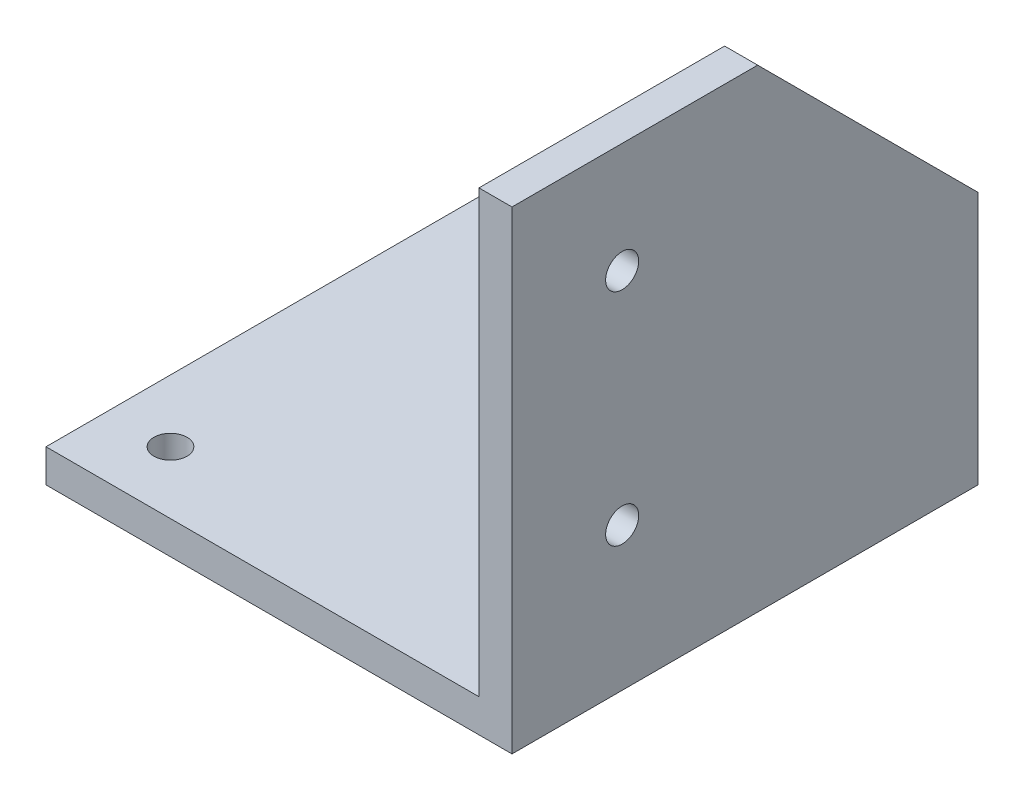
from build123d import *

# Parameters (mm, degrees)
SKETCH1_W           = 42.3
SKETCH1_H           = 42.3
BOSS_EXTRUDE1_DEPTH = 3
SKETCH2_R           = 1.5
CUT_EXTRUDE1_DEPTH  = 4
SKETCH5_W           = 3
SKETCH5_H           = 42.3
BOSS_EXTRUDE2_DEPTH = 40
CUT_EXTRUDE2_DEPTH  = 40
SKETCH7_R           = 1.5
CUT_EXTRUDE3_DEPTH  = 4


with BuildPart() as part:
    # Sketch1 → Boss-Extrude1 (new body)
    with BuildSketch(Plane(origin=(0, 0, 0), x_dir=(1, 0, 0), z_dir=(0, 1, 0))):
        with Locations((21.15, 21.15)):
            Rectangle(SKETCH1_W, SKETCH1_H)
    extrude(amount=BOSS_EXTRUDE1_DEPTH)

    # Sketch2 → Cut-Extrude1 (cut, through all)
    with BuildSketch(Plane(origin=(0, 3, 0), x_dir=(1, 0, 0), z_dir=(0, 1, 0))):
        with Locations((5.65, 5.65)):
            Circle(SKETCH2_R)
        with Locations((36.65, 5.65)):
            Circle(SKETCH2_R)
        with Locations((36.65, 36.65)):
            Circle(SKETCH2_R)
        with Locations((5.65, 36.65)):
            Circle(SKETCH2_R)
    extrude(amount=-CUT_EXTRUDE1_DEPTH, mode=Mode.SUBTRACT)

    # Sketch5 → Boss-Extrude2 (add)
    with BuildSketch(Plane(origin=(0, 3, 0), x_dir=(1, 0, 0), z_dir=(0, 1, 0))):
        with Locations((40.8, 21.15)):
            Rectangle(SKETCH5_W, SKETCH5_H)
    extrude(amount=BOSS_EXTRUDE2_DEPTH)

    # Sketch6 → Cut-Extrude2 (cut)
    with BuildSketch(Plane.ZY.offset(-39.3)):
        Polygon((-42.3, 43), (-22.3, 43), (-42.3, 23), align=None)
    extrude(amount=-CUT_EXTRUDE2_DEPTH, mode=Mode.SUBTRACT)

    # Sketch7 → Cut-Extrude3 (cut, through all)
    with BuildSketch(Plane.ZY.offset(-39.3)):
        with Locations((-10, 33)):
            Circle(SKETCH7_R)
        with Locations((-10, 13)):
            Circle(SKETCH7_R)
    extrude(amount=-CUT_EXTRUDE3_DEPTH, mode=Mode.SUBTRACT)


solid = part.part
